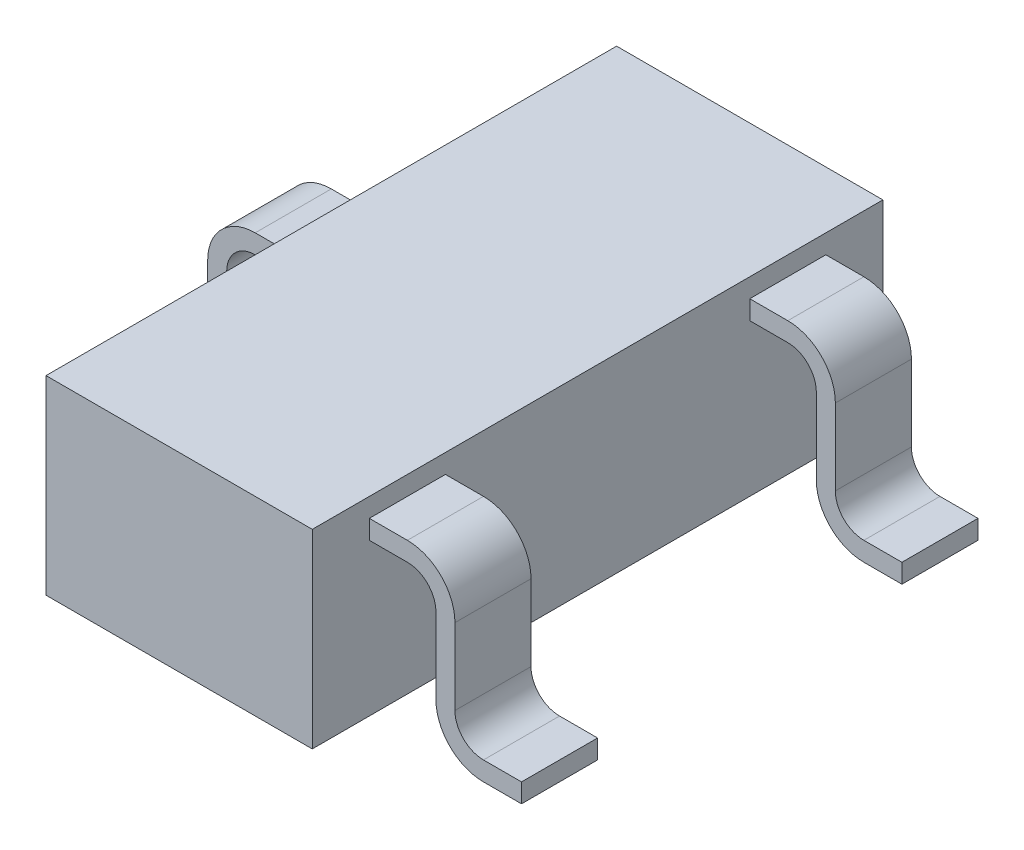
from build123d import *

# Parameters (mm, degrees)
BASES_W      = 1.4
BASES_H      = 3
BASE_DEPTH   = 0.5
LEG_DEPTH    = 0.2
MIDLEG_DEPTH = 0.2


with BuildPart() as part:
    # BaseS → Base (new body, symmetric)
    with BuildSketch(Plane(origin=(0, 0, 0), x_dir=(1, 0, 0), z_dir=(0, 1, 0))):
        Rectangle(BASES_W, BASES_H)
    extrude(amount=BASE_DEPTH, both=True)

    # LegS → Leg (add, symmetric)
    with BuildSketch(Plane.XY.offset(1)):
        with BuildLine():
            Line((1.5, -0.4), (1.3, -0.4))
            ThreePointArc((1.3, -0.4), (1.193933983, -0.356066017), (1.15, -0.25))
            Line((1.15, -0.25), (1.15, 0.15))
            ThreePointArc((1.15, 0.15), (1.076776695, 0.326776695), (0.9, 0.4))
            Line((0.9, 0.4), (0.7, 0.4))
            Line((0.7, 0.4), (0.7, 0.3))
            Line((0.7, 0.3), (0.9, 0.3))
            ThreePointArc((0.9, 0.3), (1.006066017, 0.256066017), (1.05, 0.15))
            Line((1.05, 0.15), (1.05, -0.25))
            ThreePointArc((1.05, -0.25), (1.123223305, -0.426776695), (1.3, -0.5))
            Line((1.3, -0.5), (1.5, -0.5))
            Line((1.5, -0.5), (1.5, -0.4))
        make_face()
    leg = extrude(amount=LEG_DEPTH, both=True)

    # Mirror1: Leg across plane
    add(leg.mirror(Plane.XY))


with BuildPart() as body_2:
    # MidLegS → MidLeg (new body, symmetric)
    with BuildSketch(Plane.XY):
        with BuildLine():
            Line((-0.7, 0.4), (-0.9, 0.4))
            ThreePointArc((-0.9, 0.4), (-1.076776695, 0.326776695), (-1.15, 0.15))
            Line((-1.15, 0.15), (-1.15, -0.25))
            ThreePointArc((-1.15, -0.25), (-1.193933983, -0.356066017), (-1.3, -0.4))
            Line((-1.3, -0.4), (-1.5, -0.4))
            Line((-1.5, -0.4), (-1.5, -0.5))
            Line((-1.5, -0.5), (-1.3, -0.5))
            ThreePointArc((-1.3, -0.5), (-1.123223305, -0.426776695), (-1.05, -0.25))
            Line((-1.05, -0.25), (-1.05, 0.15))
            ThreePointArc((-1.05, 0.15), (-1.006066017, 0.256066017), (-0.9, 0.3))
            Line((-0.9, 0.3), (-0.7, 0.3))
            Line((-0.7, 0.3), (-0.7, 0.4))
        make_face()
    extrude(amount=MIDLEG_DEPTH, both=True)


solid = Compound([part.part, body_2.part])
